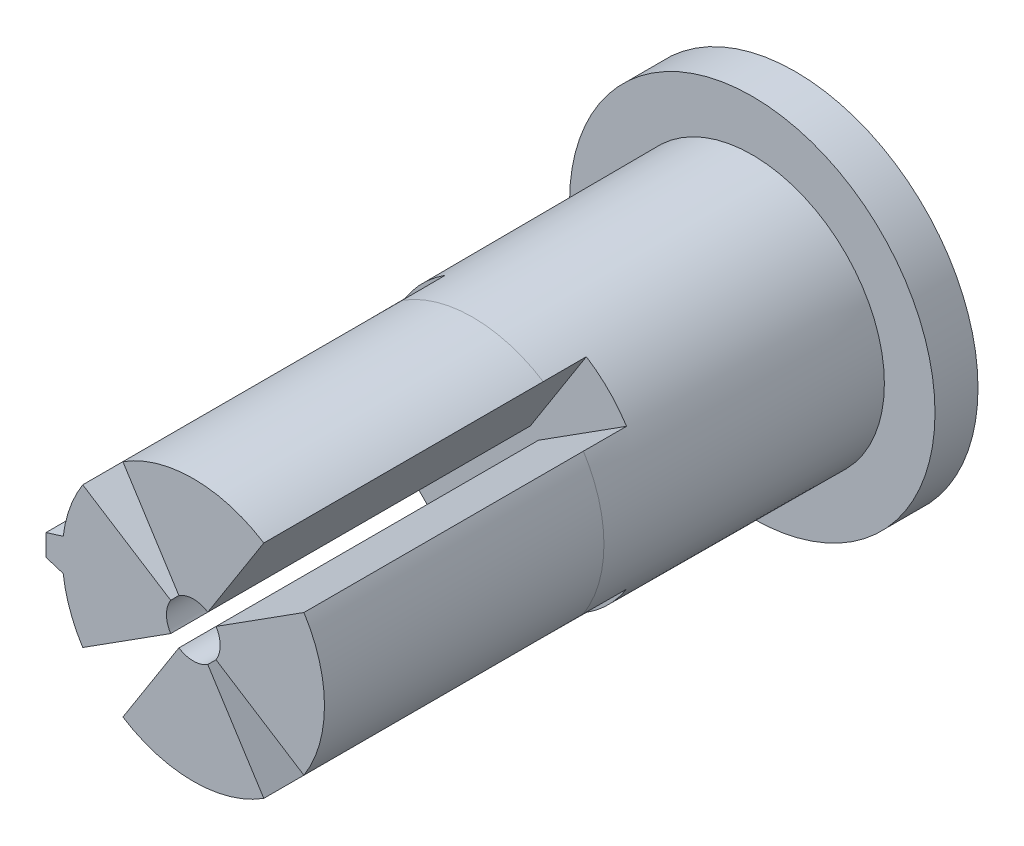
from build123d import *

# Parameters (mm, degrees)
BOSS_EXTRUDE1_DEPTH           = 13
BOSS_EXTRUDE1_OTHER_WAY_DEPTH = 13
BOSS_EXTRUDE1_OTHER_WAY_TAPER = -0.2
SKETCH3_R                     = 8.5
BOSS_EXTRUDE2_DEPTH           = 2
CUT_EXTRUDE2_DEPTH            = 12.5
SKETCH2_R                     = 1.25
CUT_EXTRUDE1_DEPTH            = 15
CUT_EXTRUDE3_DEPTH            = 15


with BuildPart() as part:
    # Sketch1 → Boss-Extrude1 (new body)
    with BuildSketch(Plane.XY):
        with BuildLine():
            ThreePointArc((-6.053717866, -0.75), (6.1, 0), (-6.053717866, 0.75))
            Line((-6.053717866, 0.75), (-6.853717866, 0.5))
            Line((-6.853717866, 0.5), (-6.853717866, -0.5))
            Line((-6.853717866, -0.5), (-6.053717866, -0.75))
        make_face()
    extrude(amount=BOSS_EXTRUDE1_DEPTH)

    # Sketch1 → Boss-Extrude1 other way (add)
    with BuildSketch(Plane.XY):
        with BuildLine():
            ThreePointArc((-6.053717866, -0.75), (6.1, 0), (-6.053717866, 0.75))
            Line((-6.053717866, 0.75), (-6.853717866, 0.5))
            Line((-6.853717866, 0.5), (-6.853717866, -0.5))
            Line((-6.853717866, -0.5), (-6.053717866, -0.75))
        make_face()
    extrude(amount=-BOSS_EXTRUDE1_OTHER_WAY_DEPTH, taper=BOSS_EXTRUDE1_OTHER_WAY_TAPER)

    # Sketch3 → Boss-Extrude2 (add)
    with BuildSketch(Plane(origin=(0, 0, -13), x_dir=(-1, 0, 0), z_dir=(0, 0, -1))):
        Circle(SKETCH3_R)
    extrude(amount=BOSS_EXTRUDE2_DEPTH)

    # Sketch4 → Cut-Extrude2 (cut)
    with BuildSketch(Plane(origin=(0, 0, -15), x_dir=(-1, 0, 0), z_dir=(0, 0, -1))):
        with BuildLine():
            Line((2.5, 1.833030278), (2.5, -1.833030278))
            ThreePointArc((2.5, -1.833030278), (-3.1, 0), (2.5, 1.833030278))
        make_face()
    extrude(amount=-CUT_EXTRUDE2_DEPTH, mode=Mode.SUBTRACT)

    # Sketch2 → Cut-Extrude1 (cut)
    with BuildSketch(Plane.XY.offset(13)):
        Circle(SKETCH2_R)
    extrude(amount=-CUT_EXTRUDE1_DEPTH, mode=Mode.SUBTRACT)

    # Sketch5 → Cut-Extrude3 (cut)
    with BuildSketch(Plane.XY.offset(13)):
        with BuildLine():
            Line((-1.054239307, 0.67162451), (-5.182959865, 3.301909593))
            ThreePointArc((-5.182959865, 3.301909593), (-4.345438983, 4.345438983), (-3.301909593, 5.182959865))
            Line((-3.301909593, 5.182959865), (-0.67162451, 1.054239307))
            ThreePointArc((-0.67162451, 1.054239307), (-0.883883476, 0.883883476), (-1.054239307, 0.67162451))
        make_face()
        with BuildLine():
            Line((0.67162451, 1.054239307), (3.301909593, 5.182959865))
            ThreePointArc((3.301909593, 5.182959865), (4.345438983, 4.345438983), (5.182959865, 3.301909593))
            Line((5.182959865, 3.301909593), (1.054239307, 0.67162451))
            ThreePointArc((1.054239307, 0.67162451), (0.883883476, 0.883883476), (0.67162451, 1.054239307))
        make_face()
        with BuildLine():
            Line((1.054239307, -0.67162451), (5.182959865, -3.301909593))
            ThreePointArc((5.182959865, -3.301909593), (4.345438983, -4.345438983), (3.301909593, -5.182959865))
            Line((3.301909593, -5.182959865), (0.67162451, -1.054239307))
            ThreePointArc((0.67162451, -1.054239307), (0.883883476, -0.883883476), (1.054239307, -0.67162451))
        make_face()
        with BuildLine():
            Line((-0.67162451, -1.054239307), (-3.301909593, -5.182959865))
            ThreePointArc((-3.301909593, -5.182959865), (-4.345438983, -4.345438983), (-5.182959865, -3.301909593))
            Line((-5.182959865, -3.301909593), (-1.054239307, -0.67162451))
            ThreePointArc((-1.054239307, -0.67162451), (-0.883883476, -0.883883476), (-0.67162451, -1.054239307))
        make_face()
    extrude(amount=-CUT_EXTRUDE3_DEPTH, mode=Mode.SUBTRACT)


solid = part.part
